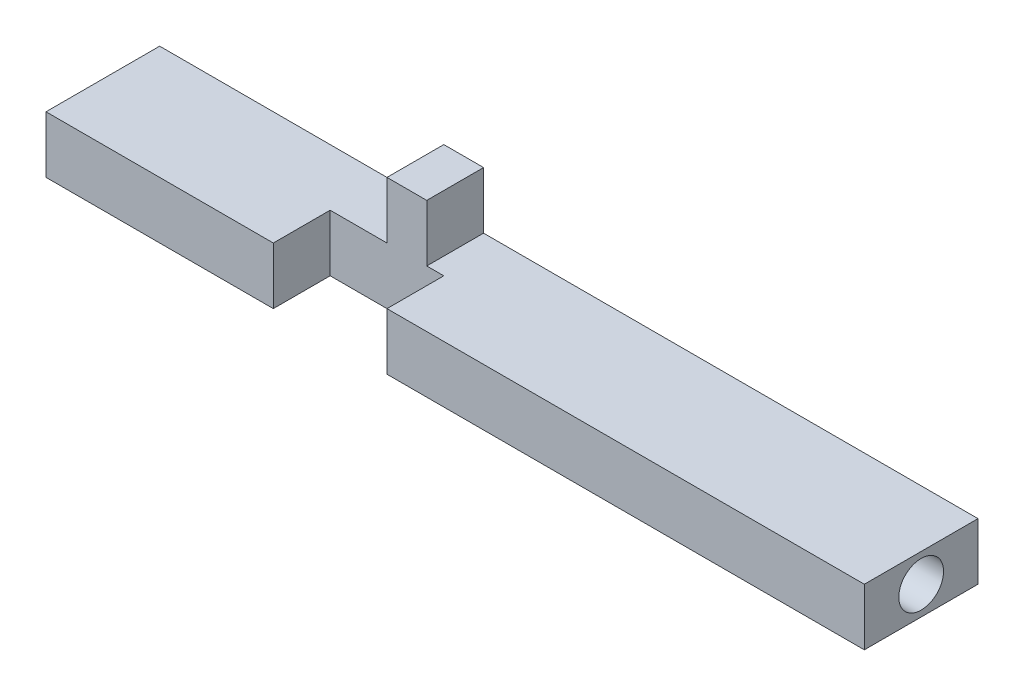
from build123d import *

# Parameters (mm, degrees)
SKETCH1_W           = 45.72
SKETCH1_H           = 6.35
BOSS_EXTRUDE1_DEPTH = 1.5875
SKETCH4_W           = 6.35
SKETCH4_H           = 3.175
CUT_EXTRUDE1_DEPTH  = 3.175
SKETCH5_W           = 2.2225
SKETCH5_H           = 3.175
BOSS_EXTRUDE3_DEPTH = 3.175
SKETCH3_R           = 1.25
CUT_EXTRUDE2_DEPTH  = 6.985


with BuildPart() as part:
    # Sketch1 → Boss-Extrude1 (new body, symmetric)
    with BuildSketch(Plane(origin=(0, 0, 0), x_dir=(1, 0, 0), z_dir=(0, 1, 0))):
        Rectangle(SKETCH1_W, SKETCH1_H)
    extrude(amount=BOSS_EXTRUDE1_DEPTH, both=True)

    # Sketch4 → Cut-Extrude1 (cut)
    with BuildSketch(Plane.XY.offset(3.175)):
        with Locations((-6.985, 0)):
            Rectangle(SKETCH4_W, SKETCH4_H)
    extrude(amount=-CUT_EXTRUDE1_DEPTH, mode=Mode.SUBTRACT)

    # Sketch5 → Boss-Extrude3 (add)
    with BuildSketch(Plane(origin=(0, 1.5875, 0), x_dir=(1, 0, 0), z_dir=(0, 1, 0))):
        with Locations((-5.87375, 1.5875)):
            Rectangle(SKETCH5_W, SKETCH5_H)
    extrude(amount=BOSS_EXTRUDE3_DEPTH)

    # Sketch3 → Cut-Extrude2 (cut)
    with BuildSketch(Plane.ZY.offset(22.86)):
        Circle(SKETCH3_R)
    cut_extrude2 = extrude(amount=-CUT_EXTRUDE2_DEPTH, mode=Mode.SUBTRACT)

    # Mirror1: Cut-Extrude2 across plane
    add(cut_extrude2.mirror(Plane(origin=(0, 0, 0), x_dir=(0, 0, 1), z_dir=(1, 0, 0))), mode=Mode.SUBTRACT)


solid = part.part
